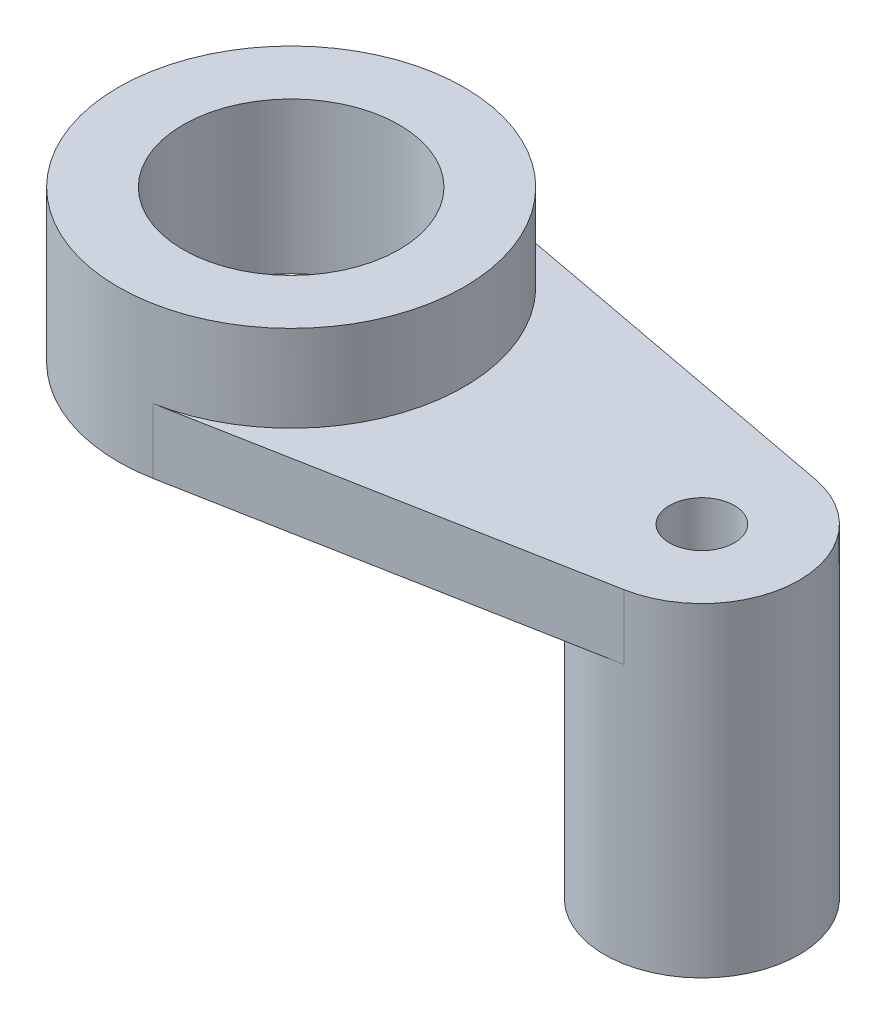
from build123d import *

# Parameters (mm, degrees)
SKETCH1_R           = 10
SKETCH1_R_2         = 3
BOSS_EXTRUDE1_DEPTH = 6
SKETCH2_R           = 16
SKETCH2_R_2         = 10
BOSS_EXTRUDE2_DEPTH = 8
SKETCH3_R           = 9
SKETCH3_R_2         = 3
BOSS_EXTRUDE3_DEPTH = 24


with BuildPart() as part:
    # Sketch1 → Boss-Extrude1 (new body)
    with BuildSketch(Plane(origin=(0, 0, 0), x_dir=(1, 0, 0), z_dir=(0, 1, 0))):
        with BuildLine():
            Line((2.947368, 15.726189), (39.657895, 8.845981))
            ThreePointArc((39.657895, 8.845981), (47, 0), (39.657895, -8.845981))
            Line((39.657895, -8.845981), (2.947368, -15.726189))
            ThreePointArc((2.947368, -15.726189), (-16, 0), (2.947368, 15.726189))
        make_face()
        Circle(SKETCH1_R, mode=Mode.SUBTRACT)
        with Locations((38, 0)):
            Circle(SKETCH1_R_2, mode=Mode.SUBTRACT)
    extrude(amount=BOSS_EXTRUDE1_DEPTH)

    # Sketch2 → Boss-Extrude2 (add)
    with BuildSketch(Plane(origin=(0, 6, 0), x_dir=(1, 0, 0), z_dir=(0, 1, 0))):
        Circle(SKETCH2_R)
        Circle(SKETCH2_R_2, mode=Mode.SUBTRACT)
    extrude(amount=BOSS_EXTRUDE2_DEPTH)

    # Sketch3 → Boss-Extrude3 (add)
    with BuildSketch(Plane.XZ):
        with Locations((38, 0)):
            Circle(SKETCH3_R)
        with Locations((38, 0)):
            Circle(SKETCH3_R_2, mode=Mode.SUBTRACT)
    extrude(amount=BOSS_EXTRUDE3_DEPTH)


solid = part.part
